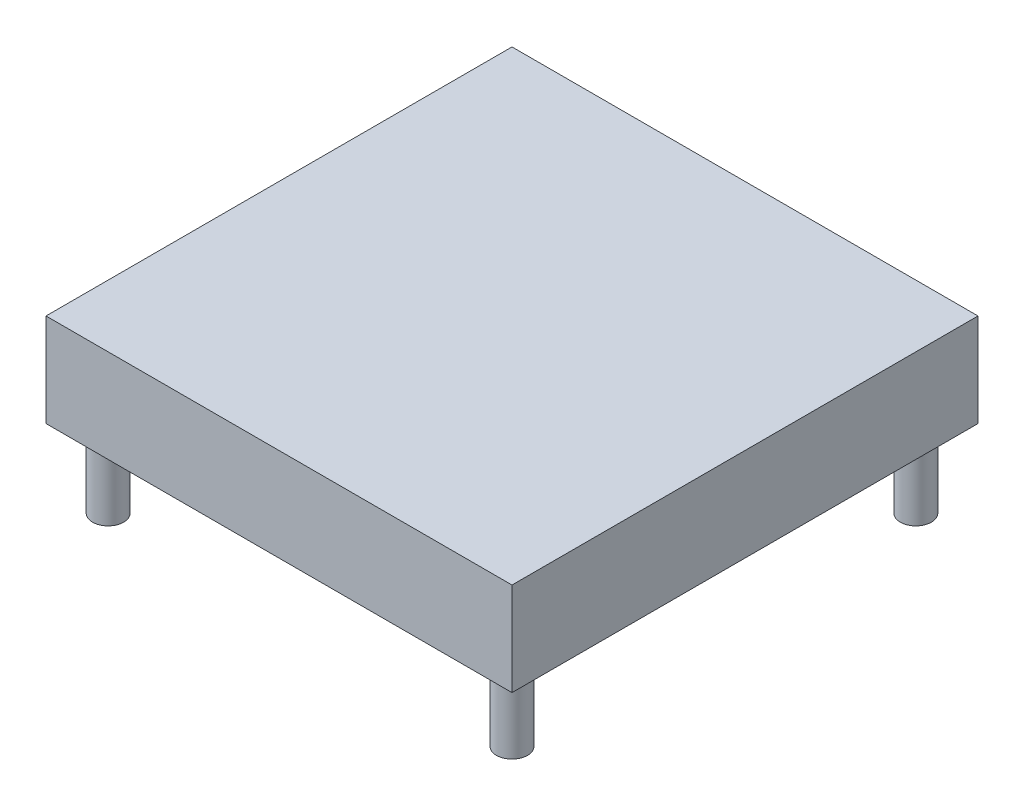
from build123d import *

# Parameters (mm, degrees)
SKETCH1_W      = 38.1
SKETCH1_H      = 38.1
EXTRUDE1_DEPTH = 7.62
SKETCH2_R      = 1.27
EXTRUDE2_DEPTH = 6.35


with BuildPart() as part:
    # Sketch1 → Extrude1 (new body)
    with BuildSketch(Plane(origin=(0, 0, 0), x_dir=(1, 0, 0), z_dir=(0, 1, 0))):
        Rectangle(SKETCH1_W, SKETCH1_H)
    extrude(amount=EXTRUDE1_DEPTH)

    # Sketch2 → Extrude2 (add)
    with BuildSketch(Plane.XZ):
        with Locations((16.51, 16.51)):
            Circle(SKETCH2_R)
        with Locations((16.51, -16.51)):
            Circle(SKETCH2_R)
        with Locations((-16.51, -16.51)):
            Circle(SKETCH2_R)
        with Locations((-16.51, 16.51)):
            Circle(SKETCH2_R)
    extrude(amount=EXTRUDE2_DEPTH)


solid = part.part
